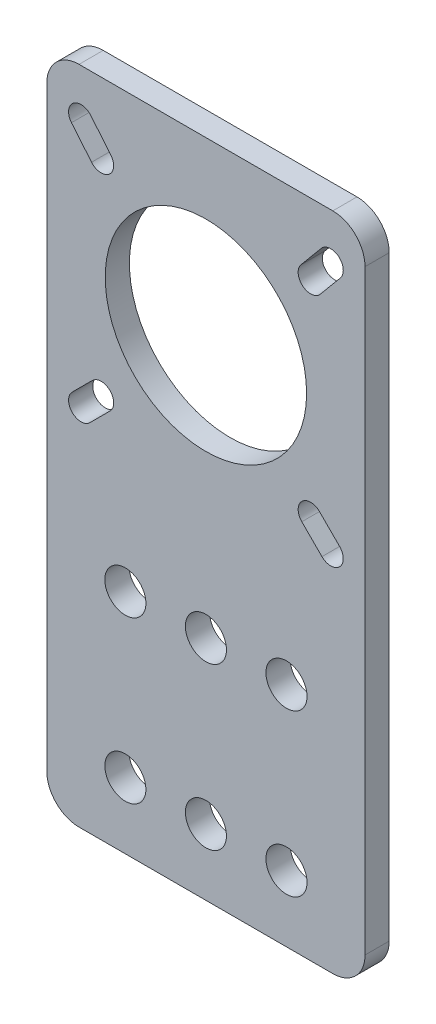
from build123d import *

# Parameters (mm, degrees)
SCHIZZO1_R                   = 12.5
SCHIZZO1_R_2                 = 2.55
ESTRUSIONE_ESTRUSIONE1_DEPTH = 3


with BuildPart() as part:
    # Schizzo1 → Estrusione-Estrusione1 (new body)
    with BuildSketch(Plane.XY):
        with BuildLine():
            Line((-15.75, -41), (15.75, -41))
            ThreePointArc((15.75, -41), (18.578427125, -39.828427125), (19.75, -37))
            Line((19.75, -37), (19.75, 37))
            ThreePointArc((19.75, 37), (18.578427125, 39.828427125), (15.75, 41))
            Line((15.75, 41), (-15.75, 41))
            ThreePointArc((-15.75, 41), (-18.578427125, 39.828427125), (-19.75, 37))
            Line((-19.75, 37), (-19.75, -37))
            ThreePointArc((-19.75, -37), (-18.578427125, -39.828427125), (-15.75, -41))
        make_face()
        with Locations((0, 19.75)):
            Circle(SCHIZZO1_R, mode=Mode.SUBTRACT)
        with Locations((-10, -12.8)):
            Circle(SCHIZZO1_R_2, mode=Mode.SUBTRACT)
        with Locations((0, -12.8)):
            Circle(SCHIZZO1_R_2, mode=Mode.SUBTRACT)
        with Locations((10, -12.8)):
            Circle(SCHIZZO1_R_2, mode=Mode.SUBTRACT)
        with Locations((10, -32.8)):
            Circle(SCHIZZO1_R_2, mode=Mode.SUBTRACT)
        with Locations((0, -32.8)):
            Circle(SCHIZZO1_R_2, mode=Mode.SUBTRACT)
        with Locations((-10, -32.8)):
            Circle(SCHIZZO1_R_2, mode=Mode.SUBTRACT)
        with BuildLine():
            Line((-14.309257017, 36.242285819), (-11.809257017, 33.242285819))
            ThreePointArc((-11.809257017, 33.242285819), (-12.007714181, 31.059257017), (-14.190742983, 31.257714181))
            Line((-14.190742983, 31.257714181), (-16.690742983, 34.257714181))
            ThreePointArc((-16.690742983, 34.257714181), (-16.492285819, 36.440742983), (-14.309257017, 36.242285819))
        make_face(mode=Mode.SUBTRACT)
        with BuildLine():
            Line((14.309257017, 36.242285819), (11.809257017, 33.242285819))
            ThreePointArc((11.809257017, 33.242285819), (12.007714181, 31.059257017), (14.190742983, 31.257714181))
            Line((14.190742983, 31.257714181), (16.690742983, 34.257714181))
            ThreePointArc((16.690742983, 34.257714181), (16.492285819, 36.440742983), (14.309257017, 36.242285819))
        make_face(mode=Mode.SUBTRACT)
        with BuildLine():
            Line((-11.903984489, 5.653984489), (-14.403984489, 3.153984489))
            ThreePointArc((-14.403984489, 3.153984489), (-16.596015511, 3.153984489), (-16.596015511, 5.346015511))
            Line((-16.596015511, 5.346015511), (-14.096015511, 7.846015511))
            ThreePointArc((-14.096015511, 7.846015511), (-11.903984489, 7.846015511), (-11.903984489, 5.653984489))
        make_face(mode=Mode.SUBTRACT)
        with BuildLine():
            Line((11.903984489, 5.653984489), (14.403984489, 3.153984489))
            ThreePointArc((14.403984489, 3.153984489), (16.596015511, 3.153984489), (16.596015511, 5.346015511))
            Line((16.596015511, 5.346015511), (14.096015511, 7.846015511))
            ThreePointArc((14.096015511, 7.846015511), (11.903984489, 7.846015511), (11.903984489, 5.653984489))
        make_face(mode=Mode.SUBTRACT)
    extrude(amount=ESTRUSIONE_ESTRUSIONE1_DEPTH)


solid = part.part
